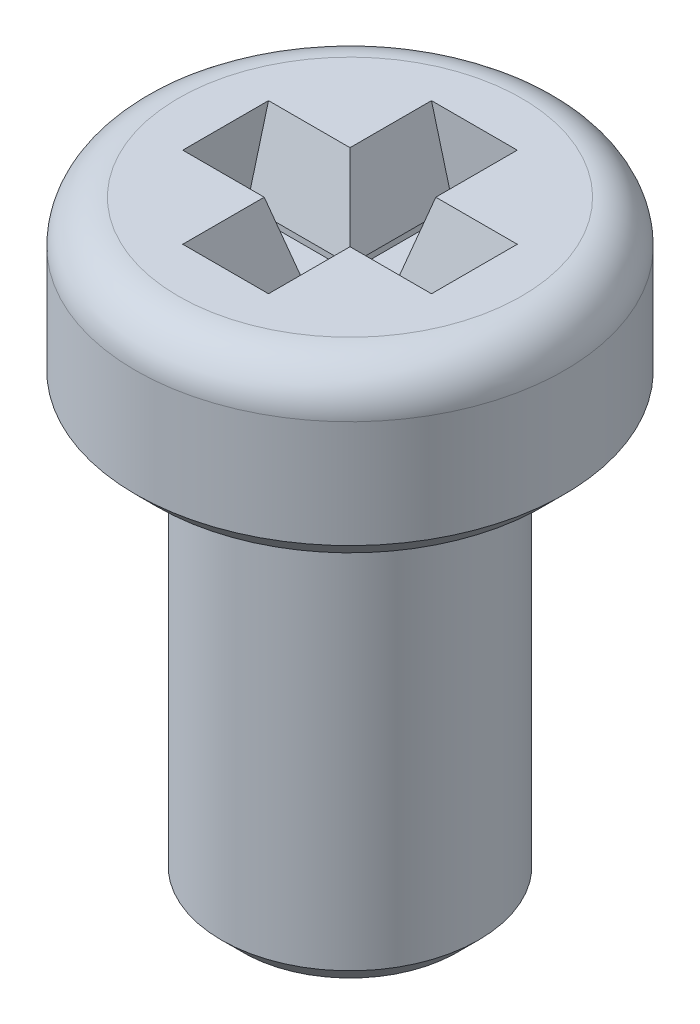
from build123d import *

# Parameters (mm, degrees)
CROQUIS1_R              = 2.5
SALIENTE_EXTRUIR1_DEPTH = 2
CROQUIS2_R              = 1.5
SALIENTE_EXTRUIR2_DEPTH = 5
CHAFL_N1_SIZE           = 0.25
REDONDEO1_R             = 0.5
CORTAR_EXTRUIR1_DEPTH   = 1
CHAFL_N2_SIZE           = 0.25
CHAFL_N2_SIZE2          = 0.933012702


with BuildPart() as part:
    # Croquis1 → Saliente-Extruir1 (new body)
    with BuildSketch(Plane(origin=(0, 0, 0), x_dir=(1, 0, 0), z_dir=(0, 1, 0))):
        Circle(CROQUIS1_R)
    extrude(amount=SALIENTE_EXTRUIR1_DEPTH)

    # Croquis2 → Saliente-Extruir2 (add)
    with BuildSketch(Plane.XZ):
        Circle(CROQUIS2_R)
    extrude(amount=SALIENTE_EXTRUIR2_DEPTH)

    # Chaflán1
    chafl_n1_edges = [part.edges().sort_by_distance(p)[0] for p in [
        (-2.5, 0, 0),
        (-1.5, -5, 0),
    ]]
    chamfer(chafl_n1_edges, length=CHAFL_N1_SIZE)

    # Redondeo1
    redondeo1_edges = [part.edges().sort_by_distance(p)[0] for p in [
        (-2.5, 2, 0),
    ]]
    fillet(redondeo1_edges, radius=REDONDEO1_R)

    # Croquis3 → Cortar-Extruir1 (cut)
    with BuildSketch(Plane(origin=(0, 2, 0), x_dir=(1, 0, 0), z_dir=(0, 1, 0))):
        Polygon((0.25, 0.25), (1.45, 0.25), (1.45, -0.25), (0.25, -0.25), (0.25, -1.45), (-0.25, -1.45), (-0.25, -0.25), (-1.45, -0.25), (-1.45, 0.25), (-0.25, 0.25), (-0.25, 1.45), (0.25, 1.45), align=None)
    extrude(amount=-CORTAR_EXTRUIR1_DEPTH, mode=Mode.SUBTRACT)

    # Chaflán2
    chafl_n2_edges = [part.edges().sort_by_distance(p)[0] for p in [
        (-0.25, 2, -0.85),
        (-0.85, 2, -0.25),
        (-0.85, 2, 0.25),
        (-0.25, 2, 0.85),
        (0.25, 2, 0.85),
        (0.85, 2, 0.25),
        (0.85, 2, -0.25),
        (0.25, 2, -0.85),
    ]]
    chafl_n2_side = [part.faces().sort_by_distance(p)[0] for p in [
        (-1.943431458, 2, 0),
    ]]
    chamfer(chafl_n2_edges, length=CHAFL_N2_SIZE, length2=CHAFL_N2_SIZE2, reference=chafl_n2_side[0])


solid = part.part
